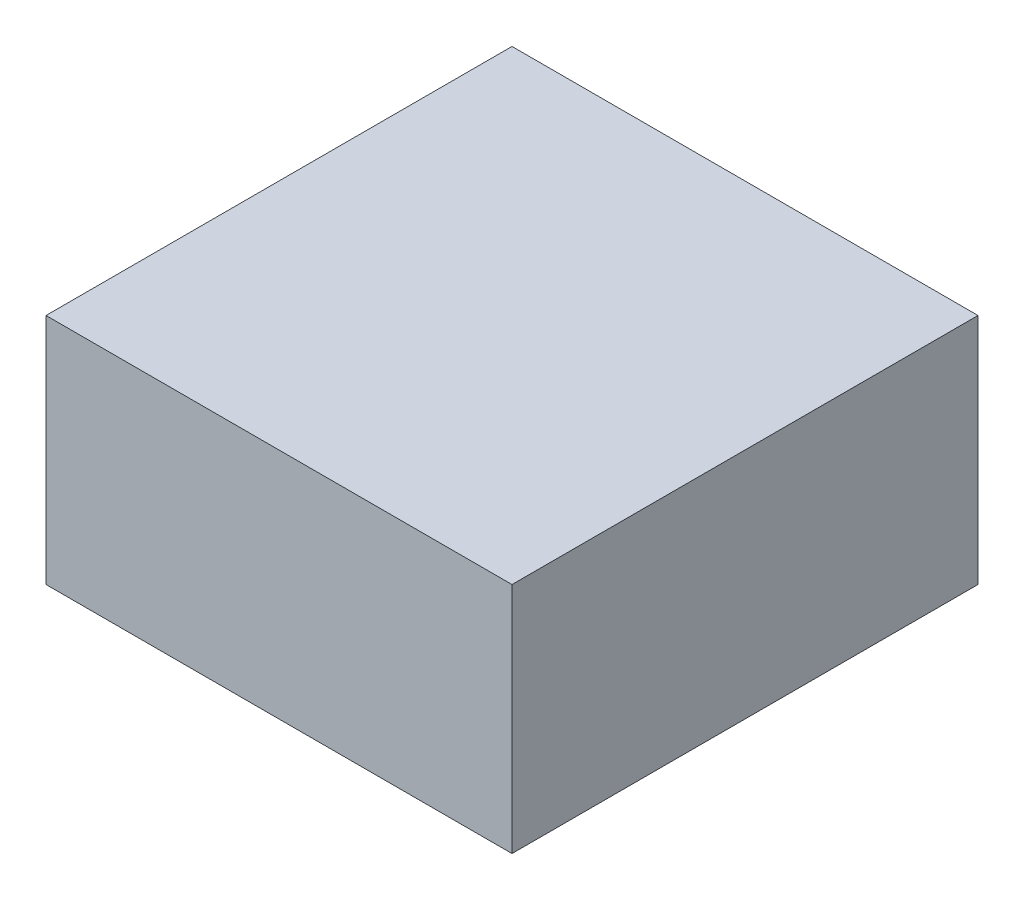
from build123d import *

# Parameters (mm, degrees)
SKETCH_1_W          = 40
SKETCH_1_H          = 40
EXTRUDE_2_DEPTH     = 20
SKETCH_2_W          = 32
SKETCH_2_H          = 12
CUT_EXTRUDE_1_DEPTH = 20


with BuildPart() as part:
    # 草图1 → 凸台-拉伸2 (new body)
    with BuildSketch(Plane(origin=(0, 0, 0), x_dir=(1, 0, 0), z_dir=(0, 1, 0))):
        with Locations((20, 20)):
            Rectangle(SKETCH_1_W, SKETCH_1_H)
    extrude(amount=EXTRUDE_2_DEPTH)

    # 草图2 → 切除-拉伸1 (cut)
    with BuildSketch(Plane.ZY):
        with Locations((-20, 10)):
            Rectangle(SKETCH_2_W, SKETCH_2_H)
    extrude(amount=-CUT_EXTRUDE_1_DEPTH, mode=Mode.SUBTRACT)


solid = part.part
